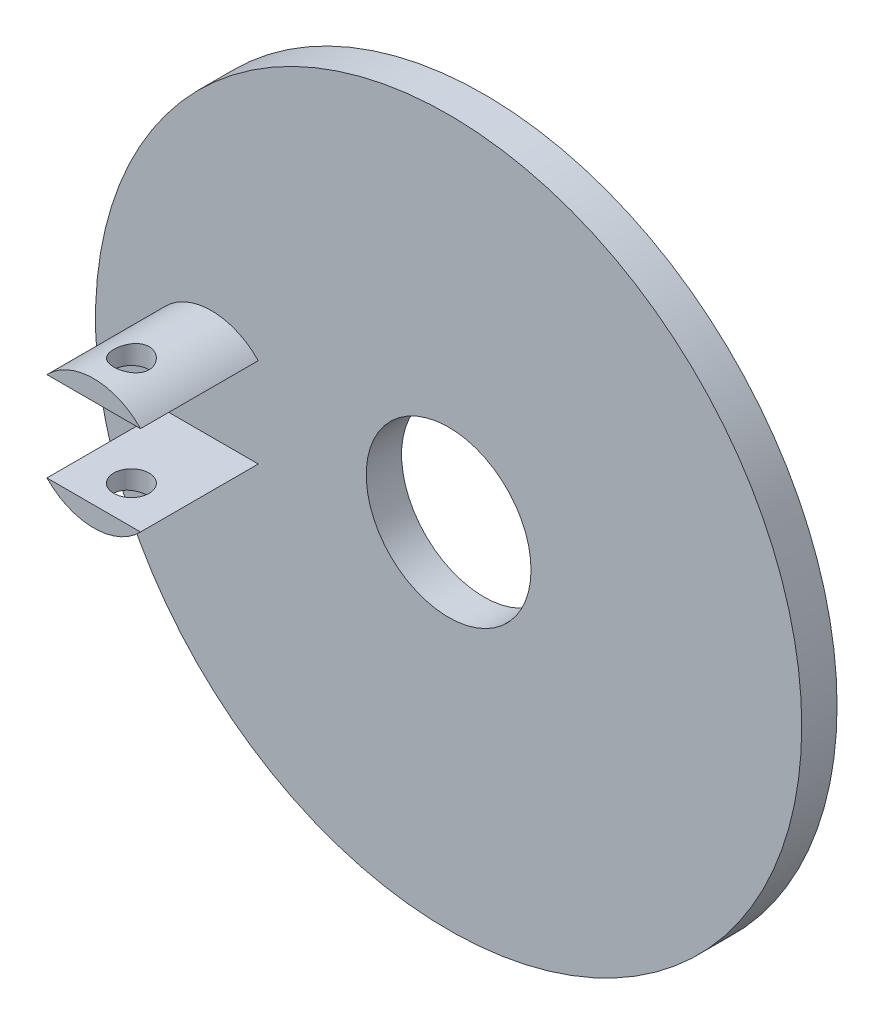
from build123d import *

# Parameters (mm, degrees)
SKETCH1_R               = 75
SKETCH1_R_2             = 17.5
BOSS_EXTRUDE2_DEPTH     = 7.5
SKETCH2_R               = 13.75
BOSS_EXTRUDE3_DEPTH     = 25
SKETCH3_OUTSIDE_W       = 194.922
SKETCH3_OUTSIDE_H       = 194.922
CUT_EXTRUDE3_DEPTH      = 25
SKETCH6_R               = 3.75
CUT_EXTRUDE4_DEPTH      = 85.5
CUT_EXTRUDE4_DEPTH_BACK = 66.5


with BuildPart() as part:
    # Sketch1 → Boss-Extrude2 (new body)
    with BuildSketch(Plane.XY):
        Circle(SKETCH1_R)
        Circle(SKETCH1_R_2, mode=Mode.SUBTRACT)
    extrude(amount=BOSS_EXTRUDE2_DEPTH)

    # Sketch2 → Boss-Extrude3 (add)
    with BuildSketch(Plane.XY.offset(7.5)):
        with Locations((-50.374404357, 0)):
            Circle(SKETCH2_R)
    extrude(amount=BOSS_EXTRUDE3_DEPTH)

    # Sketch3 outside → Cut-Extrude3 (cut)
    with BuildSketch(Plane.XY.offset(32.5)):
        Rectangle(SKETCH3_OUTSIDE_W, SKETCH3_OUTSIDE_H)
        with BuildLine():
            Line((-60.314852033, 9.5), (-40.433956681, 9.5))
            ThreePointArc((-40.433956681, 9.5), (-50.374404357, 13.75), (-60.314852033, 9.5))
        make_face(mode=Mode.SUBTRACT)
        with BuildLine():
            Line((-60.314852033, -9.5), (-40.433956681, -9.5))
            ThreePointArc((-40.433956681, -9.5), (-50.374404357, -13.75), (-60.314852033, -9.5))
        make_face(mode=Mode.SUBTRACT)
    extrude(amount=-CUT_EXTRUDE3_DEPTH, mode=Mode.SUBTRACT)

    # Sketch6 → Cut-Extrude4 (cut, two sides)
    with BuildSketch(Plane(origin=(0, -9.5, 0), x_dir=(1, 0, 0), z_dir=(0, 1, 0))) as cut_extrude4_sk:
        with Locations((-50.374404357, -24.5)):
            Circle(SKETCH6_R)
    extrude(amount=CUT_EXTRUDE4_DEPTH, mode=Mode.SUBTRACT)
    extrude(cut_extrude4_sk.sketch, amount=-CUT_EXTRUDE4_DEPTH_BACK, mode=Mode.SUBTRACT)


solid = part.part
